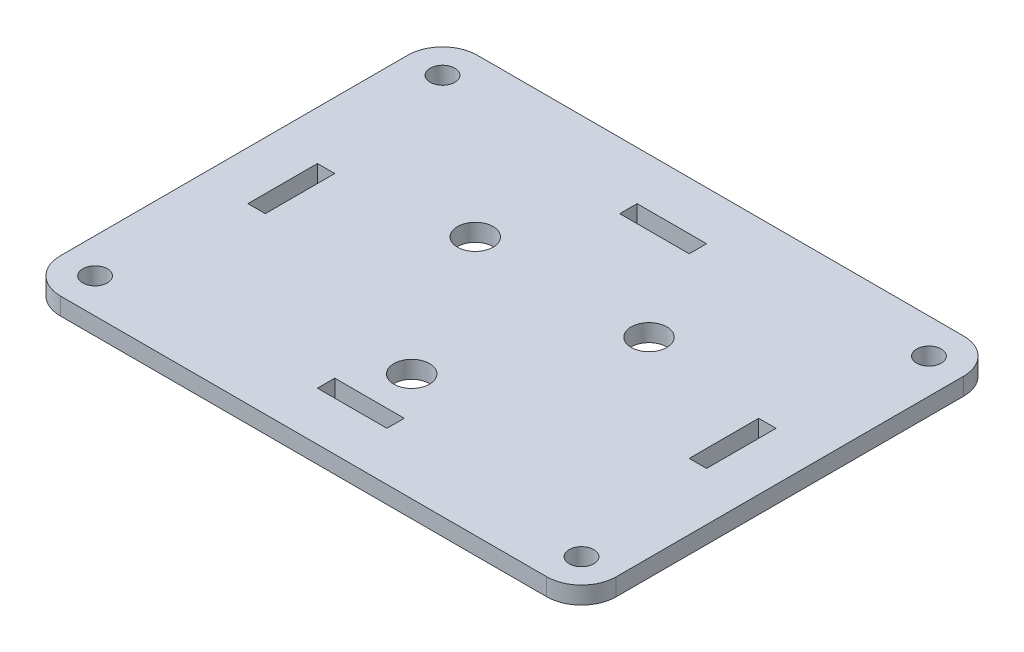
from build123d import *

# Parameters (mm, degrees)
SKETCH1_W           = 101.6
SKETCH1_H           = 76.2
BOSS_EXTRUDE1_DEPTH = 3.175
FILLET1_R           = 6.35
SKETCH2_R           = 2.2479
CUT_EXTRUDE1_DEPTH  = 4.175
SKETCH3_R           = 3.2639
CUT_EXTRUDE2_DEPTH  = 4.175


with BuildPart() as part:
    # Sketch1 → Boss-Extrude1 (new body)
    with BuildSketch(Plane(origin=(0, 0, 0), x_dir=(1, 0, 0), z_dir=(0, 1, 0))):
        Rectangle(SKETCH1_W, SKETCH1_H)
    extrude(amount=BOSS_EXTRUDE1_DEPTH)

    # Fillet1
    fillet1_edges = [part.edges().sort_by_distance(p)[0] for p in [
        (50.8, 1.5875, 38.1),
        (-50.8, 1.5875, 38.1),
        (-50.8, 1.5875, -38.1),
        (50.8, 1.5875, -38.1),
    ]]
    fillet(fillet1_edges, radius=FILLET1_R)

    # Sketch2 → Cut-Extrude1 (cut, through all)
    with BuildSketch(Plane(origin=(0, 3.175, 0), x_dir=(1, 0, 0), z_dir=(0, 1, 0))):
        with Locations((-44.45, 31.75)):
            Circle(SKETCH2_R)
        with Locations((44.45, 31.75)):
            Circle(SKETCH2_R)
        with Locations((44.45, -31.75)):
            Circle(SKETCH2_R)
        with Locations((-44.45, -31.75)):
            Circle(SKETCH2_R)
        Polygon((-41.91, 0), (-41.91, 6.35), (-38.735, 6.35), (-38.735, -6.35), (-41.91, -6.35), align=None)
        Polygon((0, 29.21), (6.35, 29.21), (6.35, 26.035), (-6.35, 26.035), (-6.35, 29.21), align=None)
        Polygon((41.91, 0), (41.91, 6.35), (38.735, 6.35), (38.735, -6.35), (41.91, -6.35), align=None)
        Polygon((0, -29.21), (6.35, -29.21), (6.35, -26.035), (-6.35, -26.035), (-6.35, -29.21), align=None)
    extrude(amount=-CUT_EXTRUDE1_DEPTH, mode=Mode.SUBTRACT)

    # Sketch3 → Cut-Extrude2 (cut, through all)
    with BuildSketch(Plane(origin=(0, 3.175, 0), x_dir=(1, 0, 0), z_dir=(0, 1, 0))):
        with Locations((-15.875, 9.165435523)):
            Circle(SKETCH3_R)
        with Locations((15.875, 9.165435523)):
            Circle(SKETCH3_R)
        with Locations((0, -18.330871047)):
            Circle(SKETCH3_R)
    extrude(amount=-CUT_EXTRUDE2_DEPTH, mode=Mode.SUBTRACT)


solid = part.part
